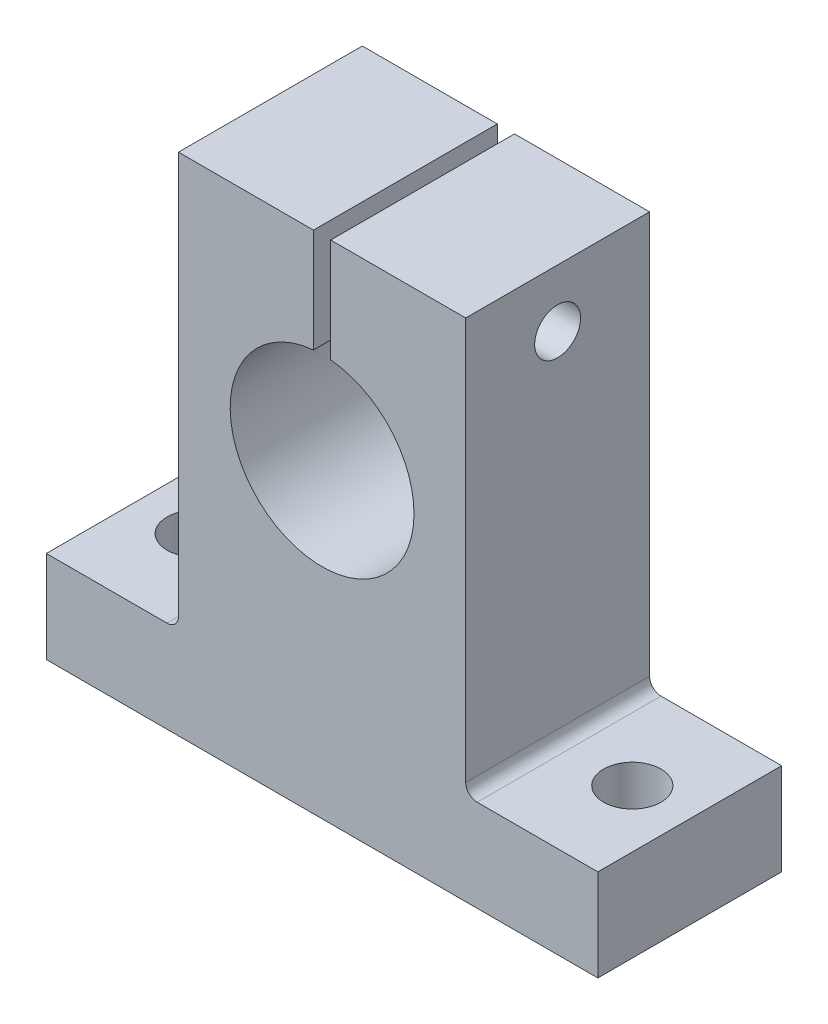
from build123d import *

# Parameters (mm, degrees)
SALIENTE_EXTRUIR1_DEPTH = 8
CROQUIS3_R              = 2.5
CORTAR_EXTRUIR1_DEPTH   = 9
REDONDEO1_R             = 1
CROQUIS4_R              = 2
CORTAR_EXTRUIR2_DEPTH   = 37.5
CROQUIS5_R              = 3.5
CORTAR_EXTRUIR3_DEPTH   = 4


with BuildPart() as part:
    # Croquis1 → Saliente-Extruir1 (new body, symmetric)
    with BuildSketch(Plane.XY):
        with BuildLine():
            Line((-24, 0), (24, 0))
            Line((24, 0), (24, 8))
            Line((24, 8), (12.5, 8))
            Line((12.5, 8), (12.5, 44))
            Line((12.5, 44), (0.75, 44))
            Line((0.75, 44), (0.75, 34.964766161))
            ThreePointArc((0.75, 34.964766161), (0, 19), (-0.75, 34.964766161))
            Line((-0.75, 34.964766161), (-0.75, 44))
            Line((-0.75, 44), (-12.5, 44))
            Line((-12.5, 44), (-12.5, 8))
            Line((-12.5, 8), (-24, 8))
            Line((-24, 8), (-24, 0))
        make_face()
    extrude(amount=SALIENTE_EXTRUIR1_DEPTH, both=True)

    # Croquis3 → Cortar-Extruir1 (cut, through all)
    with BuildSketch(Plane(origin=(0, 8, 0), x_dir=(1, 0, 0), z_dir=(0, 1, 0))):
        with Locations((-19, 0)):
            Circle(CROQUIS3_R)
        with Locations((19, 0)):
            Circle(CROQUIS3_R)
    extrude(amount=-CORTAR_EXTRUIR1_DEPTH, mode=Mode.SUBTRACT)

    # Redondeo1
    redondeo1_edges = [part.edges().sort_by_distance(p)[0] for p in [
        (-12.5, 8, 0),
        (12.5, 8, 0),
    ]]
    fillet(redondeo1_edges, radius=REDONDEO1_R)

    # Croquis4 → Cortar-Extruir2 (cut, through all)
    with BuildSketch(Plane.ZY.offset(12.5)):
        with Locations((0, 39)):
            Circle(CROQUIS4_R)
    extrude(amount=-CORTAR_EXTRUIR2_DEPTH, mode=Mode.SUBTRACT)

    # Croquis5 → Cortar-Extruir3 (cut)
    with BuildSketch(Plane.ZY.offset(12.5)):
        with Locations((0, 39)):
            Circle(CROQUIS5_R)
    extrude(amount=-CORTAR_EXTRUIR3_DEPTH, mode=Mode.SUBTRACT)


solid = part.part
